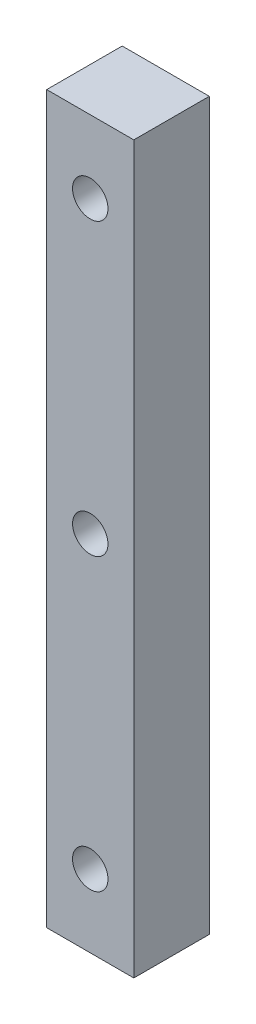
from build123d import *

# Parameters (mm, degrees)
SKETCH1_W           = 3
SKETCH1_H           = 2.6
BOSS_EXTRUDE1_DEPTH = 25
SKETCH2_R           = 0.61
CUT_EXTRUDE1_DEPTH  = 3.6


with BuildPart() as part:
    # Sketch1 → Boss-Extrude1 (new body)
    with BuildSketch(Plane(origin=(0, 0, 0), x_dir=(1, 0, 0), z_dir=(0, 1, 0))):
        with Locations((1.5, 1.3)):
            Rectangle(SKETCH1_W, SKETCH1_H)
    extrude(amount=BOSS_EXTRUDE1_DEPTH)

    # Sketch2 → Cut-Extrude1 (cut, through all)
    with BuildSketch(Plane.XY):
        with Locations((1.5, 22.5)):
            Circle(SKETCH2_R)
        with Locations((1.5, 12.5)):
            Circle(SKETCH2_R)
        with Locations((1.5, 2.5)):
            Circle(SKETCH2_R)
    extrude(amount=-CUT_EXTRUDE1_DEPTH, mode=Mode.SUBTRACT)


solid = part.part
